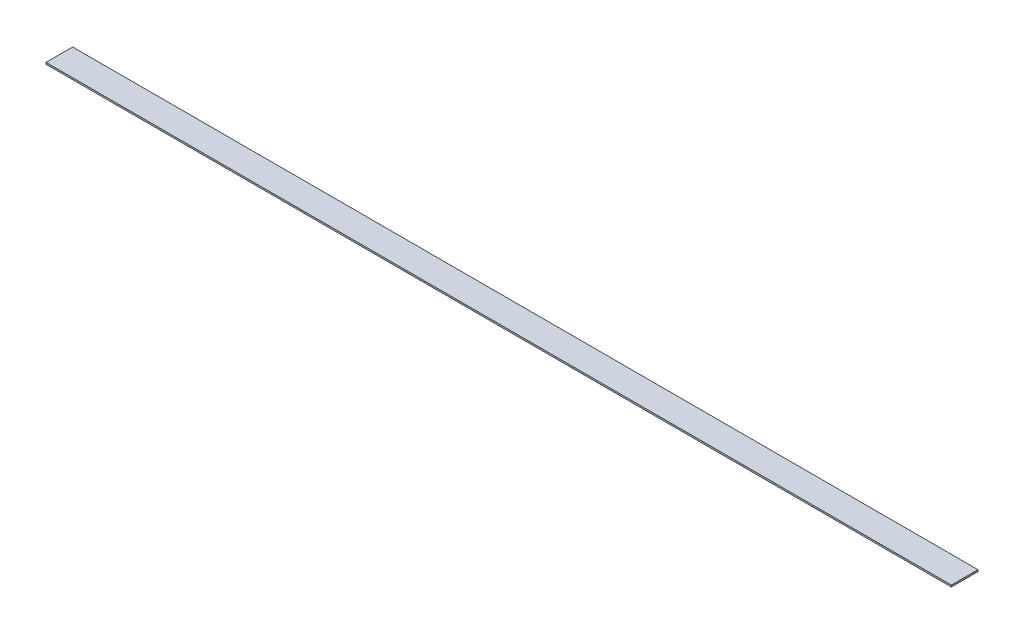
from build123d import *

# Parameters (mm, degrees)
SKETCH1_W           = 863.6
SKETCH1_H           = 25.4
BOSS_EXTRUDE1_DEPTH = 1.5875


with BuildPart() as part:
    # Sketch1 → Boss-Extrude1 (new body)
    with BuildSketch(Plane(origin=(0, 0, 0), x_dir=(1, 0, 0), z_dir=(0, 1, 0))):
        with Locations((431.8, 12.7)):
            Rectangle(SKETCH1_W, SKETCH1_H)
    extrude(amount=BOSS_EXTRUDE1_DEPTH)


solid = part.part
